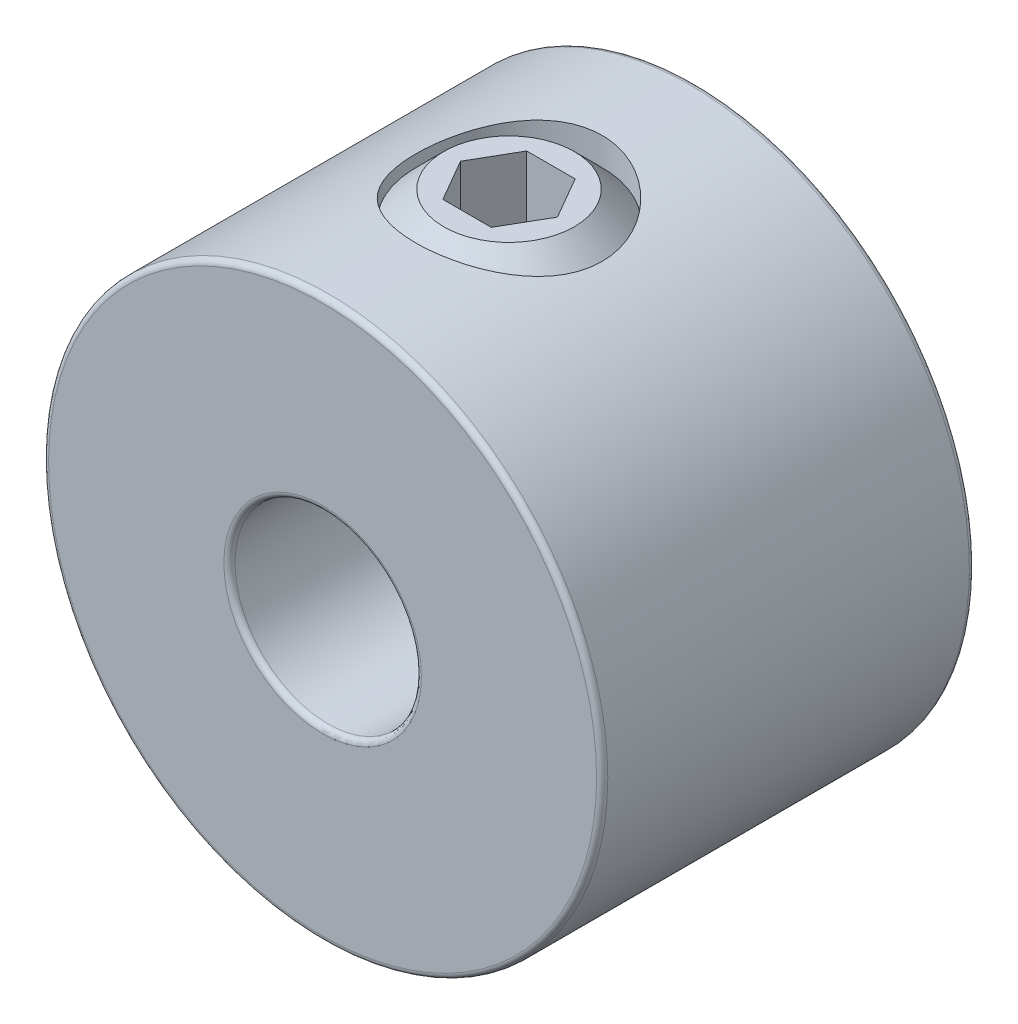
from build123d import *

# Parameters (mm, degrees)
SKETCH1_R          = 3
SKETCH1_R_2        = 1
EXTRUDE1_DEPTH     = 4
CUT_EXTRUDE1_REACH = 8
SKETCH2_R          = 1
CUT_EXTRUDE2_DEPTH = 0.72
FILLET1_R          = 0.06


with BuildPart() as part:
    # Sketch1 → Extrude1 (new body)
    with BuildSketch(Plane.XY):
        Circle(SKETCH1_R)
        Circle(SKETCH1_R_2, mode=Mode.SUBTRACT)
    extrude(amount=EXTRUDE1_DEPTH)

    # Sketch2 → Cut-Extrude1 (cut, up to next)
    with BuildSketch(Plane(origin=(0, 3, 0), x_dir=(-1, 0, 0), z_dir=(0, 1, 0)), mode=Mode.PRIVATE) as cut_extrude1_sk1:
        with Locations((0, 2)):
            Circle(SKETCH2_R)
    cut_extrude1_tool1 = extrude(cut_extrude1_sk1.sketch, amount=-CUT_EXTRUDE1_REACH, mode=Mode.PRIVATE) & part.part
    add(cut_extrude1_tool1.solids().sort_by_distance((0, 3, 2))[0], mode=Mode.SUBTRACT)

    # Fillet1
    fillet1_edges = [part.edges().sort_by_distance(p)[0] for p in [
        (-3, 0, 0),
        (-3, 0, 4),
        (-1, 0, 0),
        (-1, 0, 4),
    ]]
    fillet(fillet1_edges, radius=FILLET1_R)


with BuildPart() as body_2:
    # Sketch3 → Revolve1 (revolve)
    with BuildSketch(Plane.XY.offset(2)):
        Polygon((-0.7, 3), (-1, 2.7), (-1, 0.3), (-0.7, 0), (0, 0), (0, 3), align=None)
    revolve(axis=Axis((0, 0, 2), (0, 1, 0)))

    # Sketch4 → Cut-Extrude2 (cut)
    with BuildSketch(Plane(origin=(0, 3, 0), x_dir=(0, 0, -1), z_dir=(0, 1, 0))):
        Polygon((-2, 0.519615242), (-2.45, 0.259807621), (-2.45, -0.259807621), (-2, -0.519615242), (-1.55, -0.259807621), (-1.55, 0.259807621), align=None)
    extrude(amount=-CUT_EXTRUDE2_DEPTH, mode=Mode.SUBTRACT)


solid = Compound([part.part, body_2.part])
